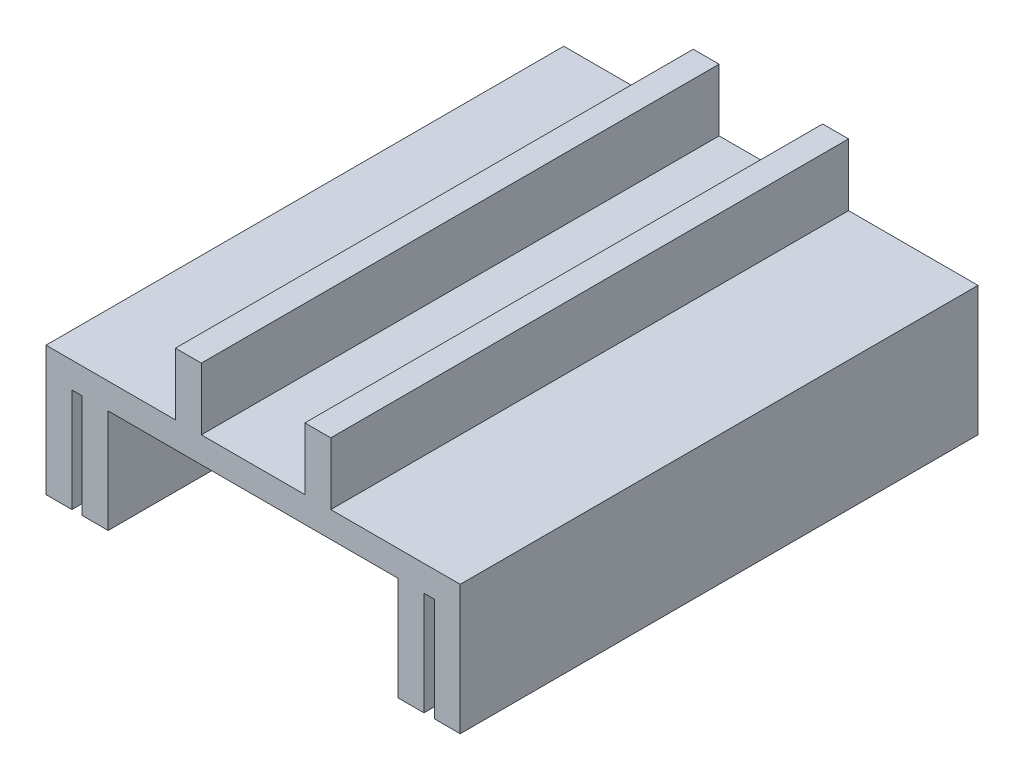
from build123d import *

# Parameters (mm, degrees)
ESQUISSE1_W        = 80
ESQUISSE1_H        = 100
BOSS_EXTRU_1_DEPTH = 5
ESQUISSE3_W        = 5
ESQUISSE3_H        = 100
BOSS_EXTRU_2_DEPTH = 20
ESQUISSE4_W        = 5
ESQUISSE4_H        = 100
BOSS_EXTRU_3_DEPTH = 12


with BuildPart() as part:
    # Esquisse1 → Boss.-Extru.1 (new body)
    with BuildSketch(Plane(origin=(0, 0, 0), x_dir=(1, 0, 0), z_dir=(0, 1, 0))):
        Rectangle(ESQUISSE1_W, ESQUISSE1_H)
    extrude(amount=BOSS_EXTRU_1_DEPTH)

    # Esquisse3 → Boss.-Extru.2 (add)
    with BuildSketch(Plane.XZ):
        with Locations((-37.5, 0)):
            Rectangle(ESQUISSE3_W, ESQUISSE3_H)
        with Locations((-30.5, 0)):
            Rectangle(ESQUISSE3_W, ESQUISSE3_H)
        with Locations((30.5, 0)):
            Rectangle(ESQUISSE3_W, ESQUISSE3_H)
        with Locations((37.5, 0)):
            Rectangle(ESQUISSE3_W, ESQUISSE3_H)
    extrude(amount=BOSS_EXTRU_2_DEPTH)

    # Esquisse4 → Boss.-Extru.3 (add)
    with BuildSketch(Plane(origin=(0, 5, 0), x_dir=(1, 0, 0), z_dir=(0, 1, 0))):
        with Locations((-12.5, 0)):
            Rectangle(ESQUISSE4_W, ESQUISSE4_H)
        with Locations((12.5, 0)):
            Rectangle(ESQUISSE4_W, ESQUISSE4_H)
    extrude(amount=BOSS_EXTRU_3_DEPTH)


solid = part.part
